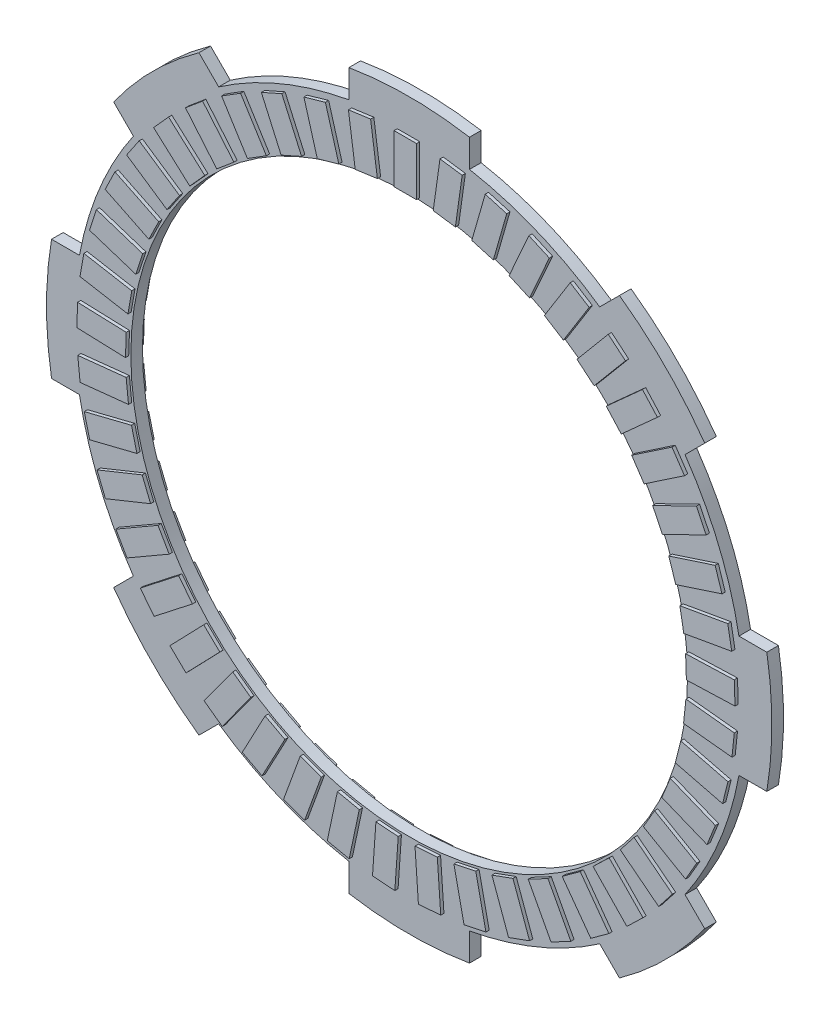
from build123d import *

# Parameters (mm, degrees)
SKETCH1_R           = 45.53
BOSS_EXTRUDE1_DEPTH = 1.9
SKETCH2_W           = 3.66
SKETCH2_H           = 7.96
BOSS_EXTRUDE2_DEPTH = 0.53
CIRPATTERN1_COUNT   = 45
SKETCH5_W           = 3.66
SKETCH5_H           = 7.96
BOSS_EXTRUDE3_DEPTH = 0.53
CIRPATTERN2_COUNT   = 45


with BuildPart() as part:
    # Sketch1 → Boss-Extrude1 (new body)
    with BuildSketch(Plane.XY):
        with BuildLine():
            Line((-48.339605955, 34.390959875), (-45.112535742, 31.163889663))
            ThreePointArc((-45.112535742, 31.163889663), (-50.656314768, 20.982532597), (-53.935577649, 9.863182231))
            Line((-53.935577649, 9.863182231), (-58.49934411, 9.863182231))
            ThreePointArc((-58.49934411, 9.863182231), (-59.325, 0), (-58.49934411, -9.863182231))
            Line((-58.49934411, -9.863182231), (-53.935577649, -9.863182231))
            ThreePointArc((-53.935577649, -9.863182231), (-50.656314768, -20.982532597), (-45.112535742, -31.163889663))
            Line((-45.112535742, -31.163889663), (-48.339605955, -34.390959875))
            ThreePointArc((-48.339605955, -34.390959875), (-41.949109794, -41.949109794), (-34.390959875, -48.339605955))
            Line((-34.390959875, -48.339605955), (-31.163889663, -45.112535742))
            ThreePointArc((-31.163889663, -45.112535742), (-20.982532597, -50.656314768), (-9.863182231, -53.935577649))
            Line((-9.863182231, -53.935577649), (-9.863182231, -58.49934411))
            ThreePointArc((-9.863182231, -58.49934411), (0, -59.325), (9.863182231, -58.49934411))
            Line((9.863182231, -58.49934411), (9.863182231, -53.935577649))
            ThreePointArc((9.863182231, -53.935577649), (20.982532597, -50.656314768), (31.163889663, -45.112535742))
            Line((31.163889663, -45.112535742), (34.390959875, -48.339605955))
            ThreePointArc((34.390959875, -48.339605955), (41.949109794, -41.949109794), (48.339605955, -34.390959875))
            Line((48.339605955, -34.390959875), (45.112535742, -31.163889663))
            ThreePointArc((45.112535742, -31.163889663), (50.656314768, -20.982532597), (53.935577649, -9.863182231))
            Line((53.935577649, -9.863182231), (58.49934411, -9.863182231))
            ThreePointArc((58.49934411, -9.863182231), (59.325, 0), (58.49934411, 9.863182231))
            Line((58.49934411, 9.863182231), (53.935577649, 9.863182231))
            ThreePointArc((53.935577649, 9.863182231), (50.656314768, 20.982532597), (45.112535742, 31.163889663))
            Line((45.112535742, 31.163889663), (48.339605955, 34.390959875))
            ThreePointArc((48.339605955, 34.390959875), (41.949109794, 41.949109794), (34.390959875, 48.339605955))
            Line((34.390959875, 48.339605955), (31.163889663, 45.112535742))
            ThreePointArc((31.163889663, 45.112535742), (20.982532597, 50.656314768), (9.863182231, 53.935577649))
            Line((9.863182231, 53.935577649), (9.863182231, 58.49934411))
            ThreePointArc((9.863182231, 58.49934411), (0, 59.325), (-9.863182231, 58.49934411))
            Line((-9.863182231, 58.49934411), (-9.863182231, 53.935577649))
            ThreePointArc((-9.863182231, 53.935577649), (-20.982532597, 50.656314768), (-31.163889663, 45.112535742))
            Line((-31.163889663, 45.112535742), (-34.390959875, 48.339605955))
            ThreePointArc((-34.390959875, 48.339605955), (-41.949109794, 41.949109794), (-48.339605955, 34.390959875))
        make_face()
        Circle(SKETCH1_R, mode=Mode.SUBTRACT)
    extrude(amount=BOSS_EXTRUDE1_DEPTH)

    # Sketch2 → Boss-Extrude2 (add)
    with BuildSketch(Plane.XY.offset(1.9)):
        with Locations((-0.108697643, 49.817516251)):
            Rectangle(SKETCH2_W, SKETCH2_H)
    boss_extrude2 = extrude(amount=BOSS_EXTRUDE2_DEPTH)

    # CirPattern1: Boss-Extrude2 ×45 about axis
    cirpattern1_axis = Axis((0, 0, 0), (0, 0, 1))
    for i in range(1, CIRPATTERN1_COUNT):
        add(boss_extrude2.rotate(cirpattern1_axis, i * 360 / CIRPATTERN1_COUNT))

    # Sketch5 → Boss-Extrude3 (add)
    with BuildSketch(Plane(origin=(0, 0, 0), x_dir=(-1, 0, 0), z_dir=(0, 0, -1))):
        with Locations((-0.321622715, 49.84341054)):
            Rectangle(SKETCH5_W, SKETCH5_H)
    boss_extrude3 = extrude(amount=BOSS_EXTRUDE3_DEPTH)

    # CirPattern2: Boss-Extrude3 ×45 about axis
    cirpattern2_axis = Axis((0, 0, 0), (0, 0, 1))
    for i in range(1, CIRPATTERN2_COUNT):
        add(boss_extrude3.rotate(cirpattern2_axis, i * 360 / CIRPATTERN2_COUNT))


solid = part.part
